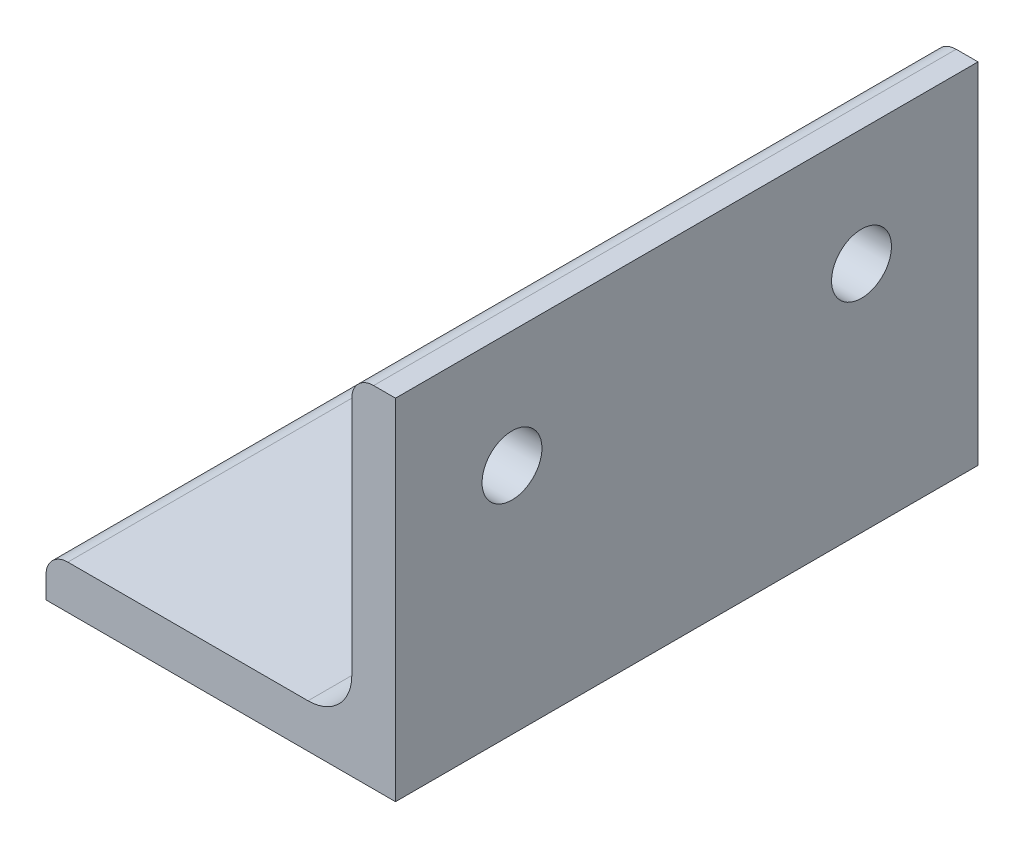
from build123d import *

# Parameters (mm, degrees)
BOSS_EXTRUDE1_DEPTH = 31.75
CUT_EXTRUDE1_REACH  = 6.762
SKETCH5_R           = 3.2639


with BuildPart() as part:
    # Sketch2 → Boss-Extrude1 (new body, symmetric)
    with BuildSketch(Plane.XY):
        with BuildLine():
            Line((-19.05, -19.05), (19.05, -19.05))
            Line((19.05, -19.05), (19.05, 19.05))
            Line((19.05, 19.05), (16.66875, 19.05))
            ThreePointArc((16.66875, 19.05), (14.984951977, 18.352548023), (14.2875, 16.66875))
            Line((14.2875, 16.66875), (14.2875, -9.5123))
            ThreePointArc((14.2875, -9.5123), (12.888876302, -12.888876302), (9.5123, -14.2875))
            Line((9.5123, -14.2875), (-16.66875, -14.2875))
            ThreePointArc((-16.66875, -14.2875), (-18.352548023, -14.984951977), (-19.05, -16.66875))
            Line((-19.05, -16.66875), (-19.05, -19.05))
        make_face()
    extrude(amount=BOSS_EXTRUDE1_DEPTH, both=True)

    # Sketch5 → Cut-Extrude1 (cut, up to next)
    with BuildSketch(Plane.ZY.offset(-14.2875), mode=Mode.PRIVATE) as cut_extrude1_sk1:
        with Locations((-19.05, 6.35)):
            Circle(SKETCH5_R)
    cut_extrude1_tool1 = extrude(cut_extrude1_sk1.sketch, amount=-CUT_EXTRUDE1_REACH, mode=Mode.PRIVATE) & part.part
    add(cut_extrude1_tool1.solids().sort_by_distance((14.2875, 6.35, -19.05))[0], mode=Mode.SUBTRACT)
    # Sketch5 → Cut-Extrude1 (cut, up to next)
    with BuildSketch(Plane.ZY.offset(-14.2875), mode=Mode.PRIVATE) as cut_extrude1_sk2:
        with Locations((19.05, 6.35)):
            Circle(SKETCH5_R)
    cut_extrude1_tool2 = extrude(cut_extrude1_sk2.sketch, amount=-CUT_EXTRUDE1_REACH, mode=Mode.PRIVATE) & part.part
    add(cut_extrude1_tool2.solids().sort_by_distance((14.2875, 6.35, 19.05))[0], mode=Mode.SUBTRACT)


solid = part.part
